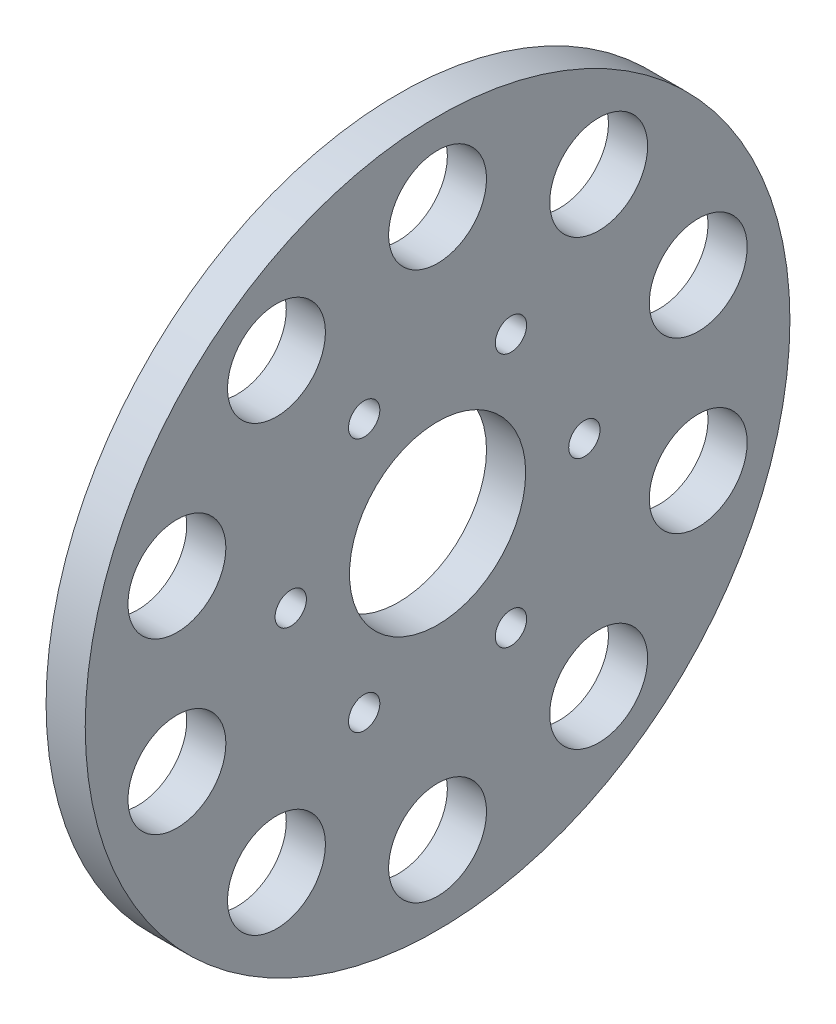
from build123d import *

# Parameters (mm, degrees)
SKETCH1_R           = 57.15
SKETCH1_R_2         = 14.2875
SKETCH1_R_3         = 7.9375
BOSS_EXTRUDE1_DEPTH = 6.35
CUT_EXTRUDE1_REACH  = 8.35
SKETCH4_R           = 2.54


with BuildPart() as part:
    # Sketch1 → Boss-Extrude1 (new body)
    with BuildSketch(Plane(origin=(0, 0, 0), x_dir=(0, 0, -1), z_dir=(1, 0, 0))):
        Circle(SKETCH1_R)
        Circle(SKETCH1_R_2, mode=Mode.SUBTRACT)
        with Locations((0, 44.45)):
            Circle(SKETCH1_R_3, mode=Mode.SUBTRACT)
        with Locations((26.127054464, 35.9608054)):
            Circle(SKETCH1_R_3, mode=Mode.SUBTRACT)
        with Locations((42.274462149, 13.7358054)):
            Circle(SKETCH1_R_3, mode=Mode.SUBTRACT)
        with Locations((42.274462149, -13.7358054)):
            Circle(SKETCH1_R_3, mode=Mode.SUBTRACT)
        with Locations((26.127054464, -35.9608054)):
            Circle(SKETCH1_R_3, mode=Mode.SUBTRACT)
        with Locations((0, -44.45)):
            Circle(SKETCH1_R_3, mode=Mode.SUBTRACT)
        with Locations((-26.127054464, -35.9608054)):
            Circle(SKETCH1_R_3, mode=Mode.SUBTRACT)
        with Locations((-42.274462149, -13.7358054)):
            Circle(SKETCH1_R_3, mode=Mode.SUBTRACT)
        with Locations((-42.274462149, 13.7358054)):
            Circle(SKETCH1_R_3, mode=Mode.SUBTRACT)
        with Locations((-26.127054464, 35.9608054)):
            Circle(SKETCH1_R_3, mode=Mode.SUBTRACT)
    extrude(amount=BOSS_EXTRUDE1_DEPTH)

    # Sketch4 → Cut-Extrude1 (cut, up to next)
    with BuildSketch(Plane.ZY, mode=Mode.PRIVATE) as cut_extrude1_sk1:
        with Locations((-11.90625, -20.622229928)):
            Circle(SKETCH4_R)
    cut_extrude1_tool1 = extrude(cut_extrude1_sk1.sketch, amount=-CUT_EXTRUDE1_REACH, mode=Mode.PRIVATE) & part.part
    add(cut_extrude1_tool1.solids().sort_by_distance((0, -20.62223, -11.90625))[0], mode=Mode.SUBTRACT)
    # Sketch4 → Cut-Extrude1 (cut, up to next)
    with BuildSketch(Plane.ZY, mode=Mode.PRIVATE) as cut_extrude1_sk2:
        with Locations((-23.8125, 0)):
            Circle(SKETCH4_R)
    cut_extrude1_tool2 = extrude(cut_extrude1_sk2.sketch, amount=-CUT_EXTRUDE1_REACH, mode=Mode.PRIVATE) & part.part
    add(cut_extrude1_tool2.solids().sort_by_distance((0, 0, -23.8125))[0], mode=Mode.SUBTRACT)
    # Sketch4 → Cut-Extrude1 (cut, up to next)
    with BuildSketch(Plane.ZY, mode=Mode.PRIVATE) as cut_extrude1_sk3:
        with Locations((-11.90625, 20.622229928)):
            Circle(SKETCH4_R)
    cut_extrude1_tool3 = extrude(cut_extrude1_sk3.sketch, amount=-CUT_EXTRUDE1_REACH, mode=Mode.PRIVATE) & part.part
    add(cut_extrude1_tool3.solids().sort_by_distance((0, 20.62223, -11.90625))[0], mode=Mode.SUBTRACT)
    # Sketch4 → Cut-Extrude1 (cut, up to next)
    with BuildSketch(Plane.ZY, mode=Mode.PRIVATE) as cut_extrude1_sk4:
        with Locations((11.90625, 20.622229928)):
            Circle(SKETCH4_R)
    cut_extrude1_tool4 = extrude(cut_extrude1_sk4.sketch, amount=-CUT_EXTRUDE1_REACH, mode=Mode.PRIVATE) & part.part
    add(cut_extrude1_tool4.solids().sort_by_distance((0, 20.62223, 11.90625))[0], mode=Mode.SUBTRACT)
    # Sketch4 → Cut-Extrude1 (cut, up to next)
    with BuildSketch(Plane.ZY, mode=Mode.PRIVATE) as cut_extrude1_sk5:
        with Locations((23.8125, 0)):
            Circle(SKETCH4_R)
    cut_extrude1_tool5 = extrude(cut_extrude1_sk5.sketch, amount=-CUT_EXTRUDE1_REACH, mode=Mode.PRIVATE) & part.part
    add(cut_extrude1_tool5.solids().sort_by_distance((0, 0, 23.8125))[0], mode=Mode.SUBTRACT)
    # Sketch4 → Cut-Extrude1 (cut, up to next)
    with BuildSketch(Plane.ZY, mode=Mode.PRIVATE) as cut_extrude1_sk6:
        with Locations((11.90625, -20.622229928)):
            Circle(SKETCH4_R)
    cut_extrude1_tool6 = extrude(cut_extrude1_sk6.sketch, amount=-CUT_EXTRUDE1_REACH, mode=Mode.PRIVATE) & part.part
    add(cut_extrude1_tool6.solids().sort_by_distance((0, -20.62223, 11.90625))[0], mode=Mode.SUBTRACT)


solid = part.part
